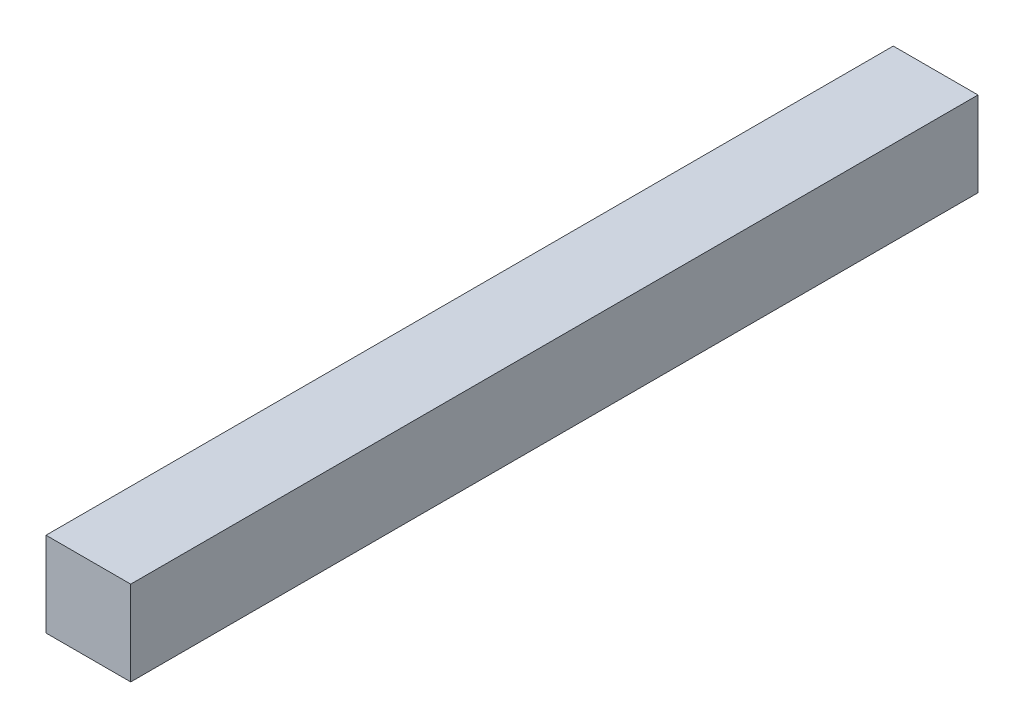
from build123d import *

# Parameters (mm, degrees)
SKETCH1_W           = 3
SKETCH1_H           = 3
BOSS_EXTRUDE1_DEPTH = 30


with BuildPart() as part:
    # Sketch1 → Boss-Extrude1 (new body)
    with BuildSketch(Plane.XY):
        with Locations((1.5, 1.5)):
            Rectangle(SKETCH1_W, SKETCH1_H)
    extrude(amount=BOSS_EXTRUDE1_DEPTH)


solid = part.part
